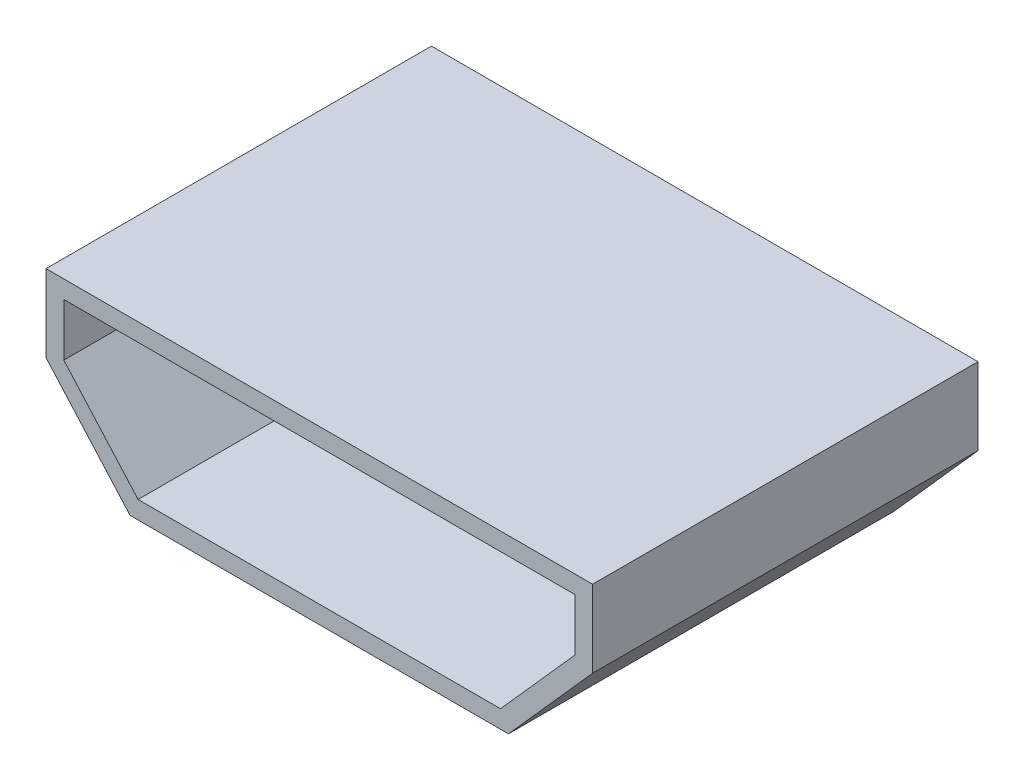
from build123d import *

# Parameters (mm, degrees)
BOSS_EXTRUDE1_DEPTH = 5.5
SHELL1_T            = -0.254


with BuildPart() as part:
    # Sketch1 → Boss-Extrude1 (new body)
    with BuildSketch(Plane.XY):
        Polygon((-2.7, 0), (2.7, 0), (3.9, 1.35), (3.9, 2.45), (-3.9, 2.45), (-3.9, 1.35), align=None)
    extrude(amount=BOSS_EXTRUDE1_DEPTH)

    # Shell1
    shell1_openings = [part.faces().sort_by_distance(p)[0] for p in [
        (0, 1.266666667, 5.5),
    ]]
    offset(amount=SHELL1_T, openings=shell1_openings, kind=Kind.INTERSECTION)


solid = part.part
